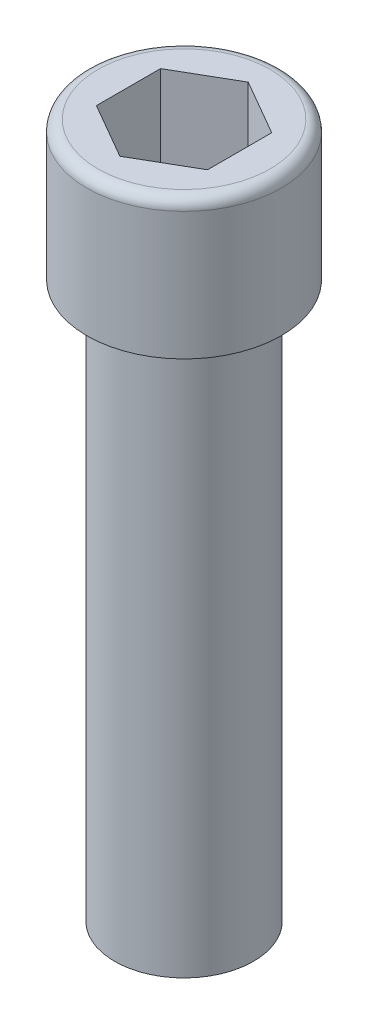
from build123d import *

# Parameters (mm, degrees)
SKETCH1_R           = 1.75
BOSS_EXTRUDE1_DEPTH = 2.5
SKETCH3_R           = 1.25
BOSS_EXTRUDE2_DEPTH = 10
FILLET1_R           = 0.2
CUT_EXTRUDE1_DEPTH  = 1.5


with BuildPart() as part:
    # Sketch1 → Boss-Extrude1 (new body)
    with BuildSketch(Plane(origin=(0, 0, 0), x_dir=(1, 0, 0), z_dir=(0, 1, 0))):
        Circle(SKETCH1_R)
    extrude(amount=BOSS_EXTRUDE1_DEPTH)

    # Sketch3 → Boss-Extrude2 (add)
    with BuildSketch(Plane.XZ):
        Circle(SKETCH3_R)
    extrude(amount=BOSS_EXTRUDE2_DEPTH)

    # Fillet1
    fillet1_edges = [part.edges().sort_by_distance(p)[0] for p in [
        (-1.75, 2.5, 0),
    ]]
    fillet(fillet1_edges, radius=FILLET1_R)

    # Sketch4 → Cut-Extrude1 (cut)
    with BuildSketch(Plane(origin=(0, 2.5, 0), x_dir=(1, 0, 0), z_dir=(0, 1, 0))):
        Polygon((0, -1.154700538), (1, -0.577350269), (1, 0.577350269), (0, 1.154700538), (-1, 0.577350269), (-1, -0.577350269), align=None)
    extrude(amount=-CUT_EXTRUDE1_DEPTH, mode=Mode.SUBTRACT)


solid = part.part
